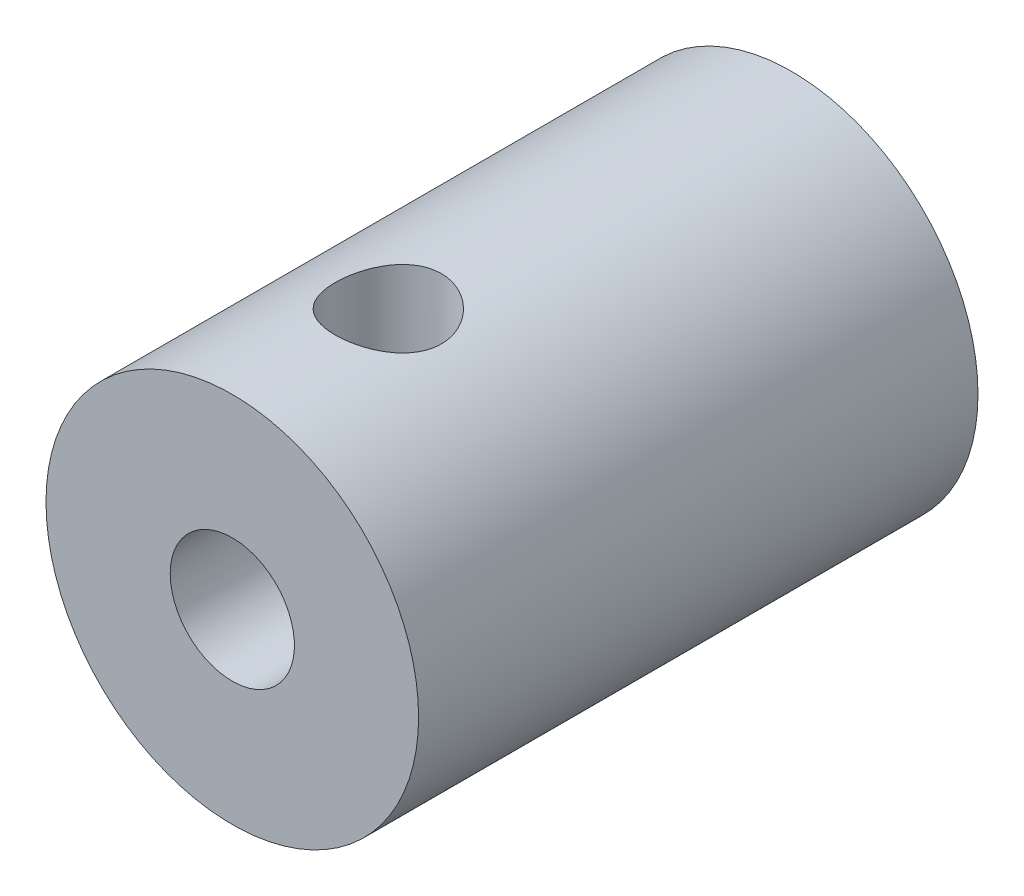
from build123d import *

# Parameters (mm, degrees)
SKETCH1_R           = 4.7625
BOSS_EXTRUDE1_DEPTH = 14.3002
SKETCH2_R           = 1.5875
CUT_EXTRUDE1_DEPTH  = 16.806914074
SKETCH2_3_R         = 3.175
SKETCH2_3_R_2       = 1.5875
CUT_EXTRUDE2_DEPTH  = 6.35
SKETCH4_R           = 1.3589
CUT_EXTRUDE3_DEPTH  = 18.829827573


with BuildPart() as part:
    # Sketch1 → Boss-Extrude1 (new body)
    with BuildSketch(Plane.XY):
        Circle(SKETCH1_R)
    extrude(amount=BOSS_EXTRUDE1_DEPTH)

    # Sketch2 → Cut-Extrude1 (cut, through all)
    with BuildSketch(Plane(origin=(0, 0, 0), x_dir=(-1, 0, 0), z_dir=(0, 0, -1))):
        Circle(SKETCH2_R)
    extrude(amount=-CUT_EXTRUDE1_DEPTH, mode=Mode.SUBTRACT)

    # Sketch2_3 → Cut-Extrude2 (cut)
    with BuildSketch(Plane(origin=(0, 0, 0), x_dir=(-1, 0, 0), z_dir=(0, 0, -1))):
        Circle(SKETCH2_3_R)
        Circle(SKETCH2_3_R_2, mode=Mode.SUBTRACT)
    extrude(amount=-CUT_EXTRUDE2_DEPTH, mode=Mode.SUBTRACT)

    # Sketch4 → Cut-Extrude3 (cut, through all)
    with BuildSketch(Plane(origin=(0, 4.7625, 0), x_dir=(1, 0, 0), z_dir=(0, 1, 0))):
        with Locations((0, -10.3124)):
            Circle(SKETCH4_R)
    extrude(amount=-CUT_EXTRUDE3_DEPTH, mode=Mode.SUBTRACT)


solid = part.part
